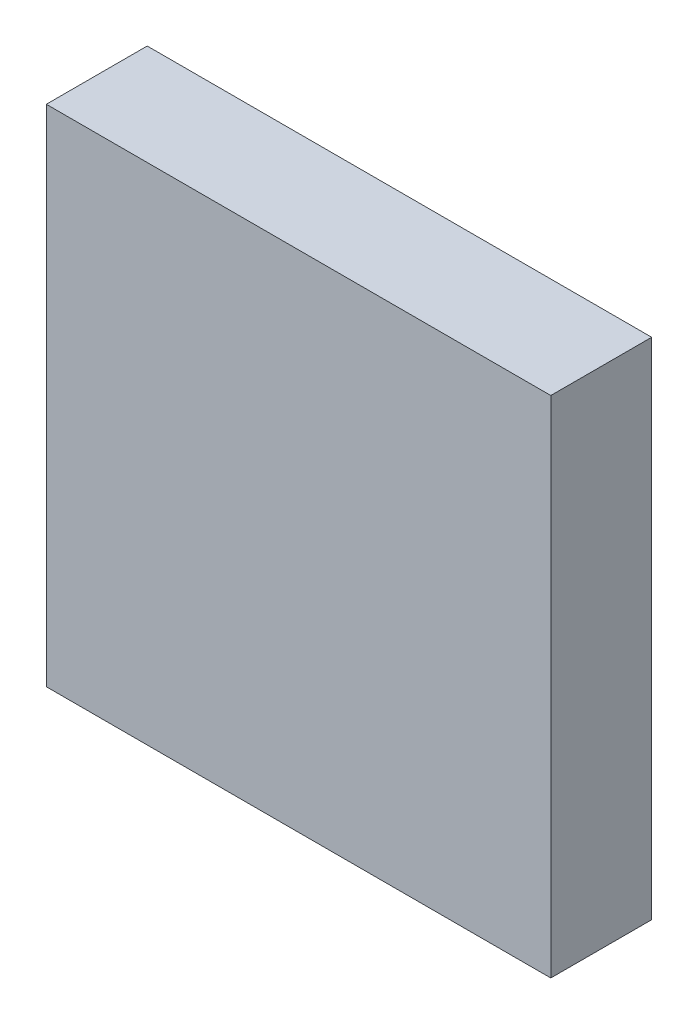
from build123d import *

# Parameters (mm, degrees)
SKETCH_1_W      = 20
SKETCH_1_H      = 20
EXTRUDE_1_DEPTH = 4


with BuildPart() as part:
    # Эскиз1 → Бобышка-Вытянуть1 (new body)
    with BuildSketch(Plane.XY):
        Rectangle(SKETCH_1_W, SKETCH_1_H)
    extrude(amount=EXTRUDE_1_DEPTH)


solid = part.part
